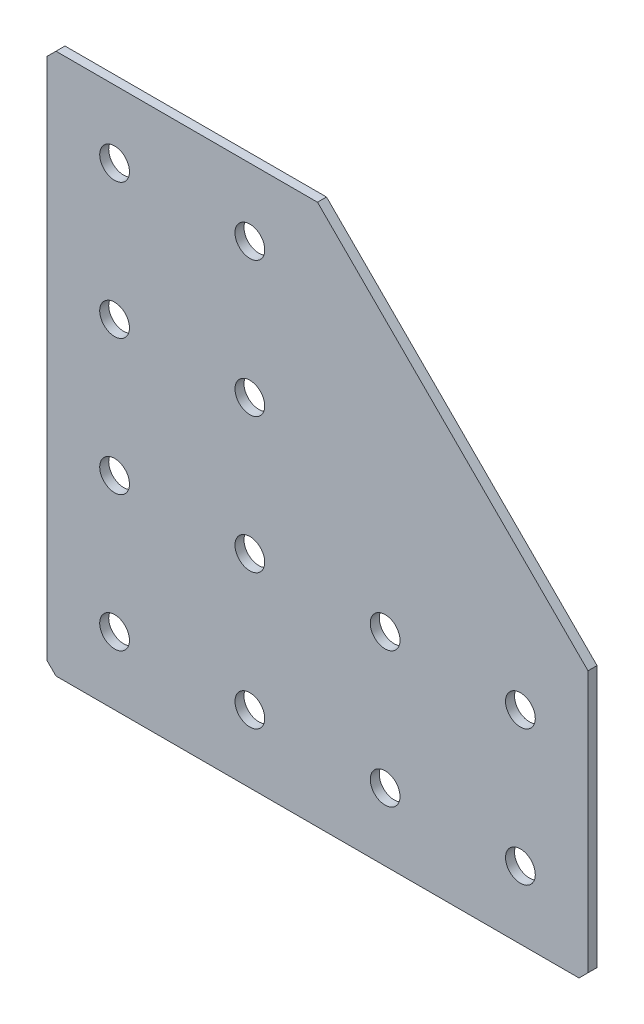
from build123d import *

# Parameters (mm, degrees)
EXTRUDE_1_DEPTH   = 2
HOLE_WIZARD_M61_D = 6.6
CHAMFER_1_SIZE    = 2


with BuildPart() as part:
    # Эскиз1 → Бобышка-Вытянуть1 (new body)
    with BuildSketch(Plane(origin=(0, 0, 0), x_dir=(1, 0, 0), z_dir=(0, 0, -1))):
        Polygon((0, 0), (0, 120), (120, 120), (120, 60), (60, 0), align=None)
    extrude(amount=EXTRUDE_1_DEPTH)

    # Отверстие с зазором M61 (through all)
    with Locations(Plane(origin=(0, 0, -2), x_dir=(1, 0, 0), z_dir=(0, 0, -1))):
        with Locations((15, 105), (15, 75), (15, 45), (15, 15), (45, 105), (45, 75), (45, 45), (45, 15), (75, 105), (75, 75), (105, 105), (105, 75)):
            Hole(HOLE_WIZARD_M61_D / 2)

    # Фаска1
    chamfer_1_edges = [part.edges().sort_by_distance(p)[0] for p in [
        (0, 0, -1),
        (0, -120, -1),
        (120, -120, -1),
    ]]
    chamfer(chamfer_1_edges, length=CHAMFER_1_SIZE)


solid = part.part
